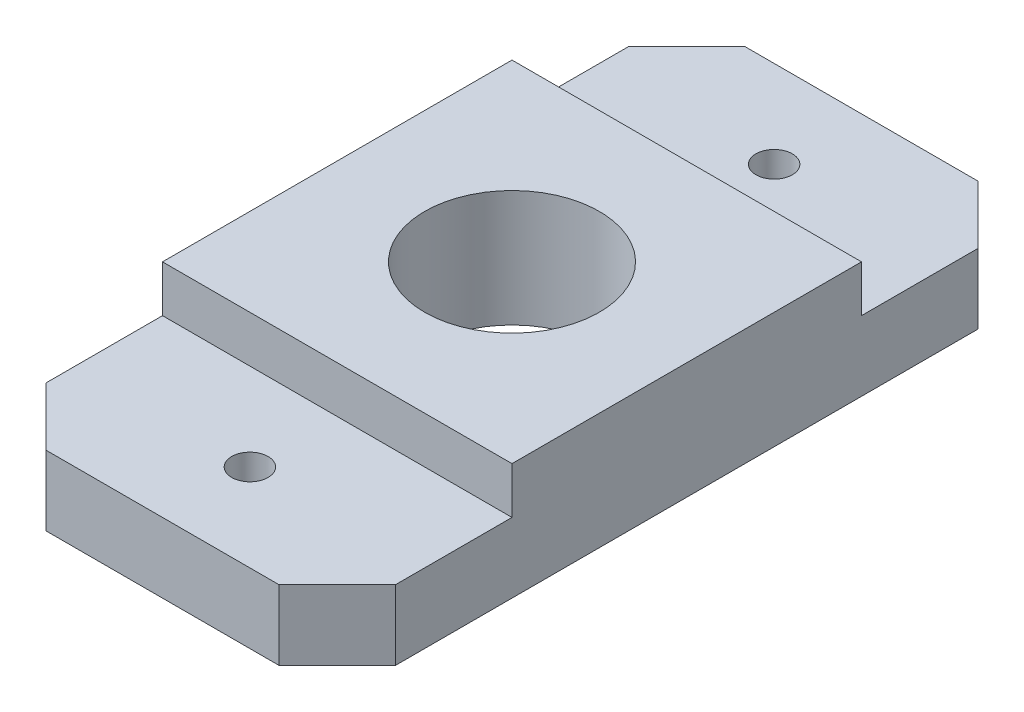
from build123d import *

# Parameters (mm, degrees)
SKETCH1_W           = 76.2
SKETCH1_H           = 76.2
BOSS_EXTRUDE1_DEPTH = 7.62
SKETCH2_W           = 38.1
SKETCH2_H           = 38.1
BOSS_EXTRUDE2_DEPTH = 5.08
SKETCH3_R           = 9.525
CUT_EXTRUDE1_DEPTH  = 13.7
SKETCH4_R           = 1.984375
CUT_EXTRUDE2_DEPTH  = 13.7
CUT_EXTRUDE3_DEPTH  = 8.62
CHAMFER1_SIZE       = 6.35


with BuildPart() as part:
    # Sketch1 → Boss-Extrude1 (new body)
    with BuildSketch(Plane(origin=(0, 0, 0), x_dir=(1, 0, 0), z_dir=(0, 1, 0))):
        Rectangle(SKETCH1_W, SKETCH1_H)
    extrude(amount=BOSS_EXTRUDE1_DEPTH)

    # Sketch2 → Boss-Extrude2 (add)
    with BuildSketch(Plane(origin=(0, 7.62, 0), x_dir=(1, 0, 0), z_dir=(0, 1, 0))):
        Rectangle(SKETCH2_W, SKETCH2_H)
    extrude(amount=BOSS_EXTRUDE2_DEPTH)

    # Sketch3 → Cut-Extrude1 (cut, through all)
    with BuildSketch(Plane(origin=(0, 12.7, 0), x_dir=(1, 0, 0), z_dir=(0, 1, 0))):
        Circle(SKETCH3_R)
    extrude(amount=-CUT_EXTRUDE1_DEPTH, mode=Mode.SUBTRACT)

    # Sketch4 → Cut-Extrude2 (cut, through all)
    with BuildSketch(Plane(origin=(0, 12.7, 0), x_dir=(1, 0, 0), z_dir=(0, 1, 0))):
        with Locations((0, 28.575)):
            Circle(SKETCH4_R)
        with Locations((0, -28.575)):
            Circle(SKETCH4_R)
    extrude(amount=-CUT_EXTRUDE2_DEPTH, mode=Mode.SUBTRACT)

    # Sketch5 → Cut-Extrude3 (cut, through all)
    with BuildSketch(Plane(origin=(0, 7.62, 0), x_dir=(1, 0, 0), z_dir=(0, 1, 0))):
        Polygon((-38.1, -38.1), (-19.05, -38.1), (-19.05, 19.05), (-19.05, 38.1), (-38.1, 38.1), (-38.1, 19.05), align=None)
        Polygon((19.05, 38.1), (19.05, 19.05), (19.05, -38.1), (38.1, -38.1), (38.1, 19.05), (38.1, 38.1), align=None)
    extrude(amount=-CUT_EXTRUDE3_DEPTH, mode=Mode.SUBTRACT)

    # Chamfer1
    chamfer1_edges = [part.edges().sort_by_distance(p)[0] for p in [
        (-19.05, 3.81, -38.1),
        (-19.05, 3.81, 38.1),
        (19.05, 3.81, -38.1),
        (19.05, 3.81, 38.1),
    ]]
    chamfer(chamfer1_edges, length=CHAMFER1_SIZE)


solid = part.part
